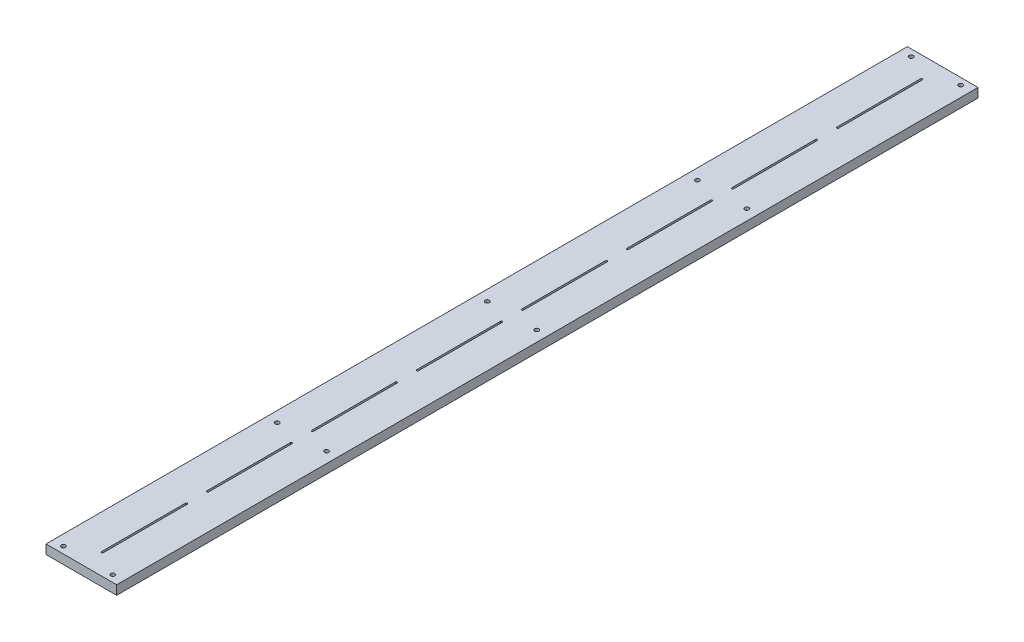
from build123d import *

# Parameters (mm, degrees)
SKETCH1_W           = 100
SKETCH1_H           = 1219.2
BOSS_EXTRUDE1_DEPTH = 13
SKETCH6_R           = 3
CUT_EXTRUDE4_DEPTH  = 20
CUT_EXTRUDE5_DEPTH  = 30


with BuildPart() as part:
    # Sketch1 → Boss-Extrude1 (new body)
    with BuildSketch(Plane(origin=(0, 0, 0), x_dir=(1, 0, 0), z_dir=(0, 1, 0))):
        Rectangle(SKETCH1_W, SKETCH1_H)
    extrude(amount=BOSS_EXTRUDE1_DEPTH)

    # Sketch6 → Cut-Extrude4 (cut)
    with BuildSketch(Plane(origin=(0, 13, 0), x_dir=(1, 0, 0), z_dir=(0, 1, 0))):
        with Locations((35, 0)):
            Circle(SKETCH6_R)
        with Locations((-35, 0)):
            Circle(SKETCH6_R)
        with Locations((35, -297.3)):
            Circle(SKETCH6_R)
        with Locations((-35, -297.3)):
            Circle(SKETCH6_R)
        with Locations((35, 600.1)):
            Circle(SKETCH6_R)
        with Locations((-35, 600.1)):
            Circle(SKETCH6_R)
        with Locations((-35, 297.3)):
            Circle(SKETCH6_R)
        with Locations((35, 297.3)):
            Circle(SKETCH6_R)
        with Locations((-35, -600.1)):
            Circle(SKETCH6_R)
        with Locations((35, -600.1)):
            Circle(SKETCH6_R)
    extrude(amount=-CUT_EXTRUDE4_DEPTH, mode=Mode.SUBTRACT)

    # Sketch7 → Cut-Extrude5 (cut)
    with BuildSketch(Plane(origin=(0, 13, 0), x_dir=(1, 0, 0), z_dir=(0, 1, 0))):
        with BuildLine():
            Line((1.3, -460.95), (1.3, -579.6))
            ThreePointArc((1.3, -579.6), (0, -580.9), (-1.3, -579.6))
            Line((-1.3, -579.6), (-1.3, -460.95))
            ThreePointArc((-1.3, -460.95), (0, -459.65), (1.3, -460.95))
        make_face()
        with BuildLine():
            Line((1.3, -312.3), (1.3, -430.95))
            ThreePointArc((1.3, -430.95), (0, -432.25), (-1.3, -430.95))
            Line((-1.3, -430.95), (-1.3, -312.3))
            ThreePointArc((-1.3, -312.3), (0, -311), (1.3, -312.3))
        make_face()
        with BuildLine():
            Line((1.3, -163.65), (1.3, -282.3))
            ThreePointArc((1.3, -282.3), (0, -283.6), (-1.3, -282.3))
            Line((-1.3, -282.3), (-1.3, -163.65))
            ThreePointArc((-1.3, -163.65), (0, -162.35), (1.3, -163.65))
        make_face()
        with BuildLine():
            Line((1.3, -15), (1.3, -133.65))
            ThreePointArc((1.3, -133.65), (0, -134.95), (-1.3, -133.65))
            Line((-1.3, -133.65), (-1.3, -15))
            ThreePointArc((-1.3, -15), (0, -13.7), (1.3, -15))
        make_face()
        with BuildLine():
            Line((1.3, 133.65), (1.3, 15))
            ThreePointArc((1.3, 15), (0, 13.7), (-1.3, 15))
            Line((-1.3, 15), (-1.3, 133.65))
            ThreePointArc((-1.3, 133.65), (0, 134.95), (1.3, 133.65))
        make_face()
        with BuildLine():
            Line((1.3, 282.3), (1.3, 163.65))
            ThreePointArc((1.3, 163.65), (0, 162.35), (-1.3, 163.65))
            Line((-1.3, 163.65), (-1.3, 282.3))
            ThreePointArc((-1.3, 282.3), (0, 283.6), (1.3, 282.3))
        make_face()
        with BuildLine():
            Line((1.3, 430.95), (1.3, 312.3))
            ThreePointArc((1.3, 312.3), (0, 311), (-1.3, 312.3))
            Line((-1.3, 312.3), (-1.3, 430.95))
            ThreePointArc((-1.3, 430.95), (0, 432.25), (1.3, 430.95))
        make_face()
        with BuildLine():
            Line((1.3, 579.6), (1.3, 460.95))
            ThreePointArc((1.3, 460.95), (0, 459.65), (-1.3, 460.95))
            Line((-1.3, 460.95), (-1.3, 579.6))
            ThreePointArc((-1.3, 579.6), (0, 580.9), (1.3, 579.6))
        make_face()
    extrude(amount=-CUT_EXTRUDE5_DEPTH, mode=Mode.SUBTRACT)


solid = part.part
